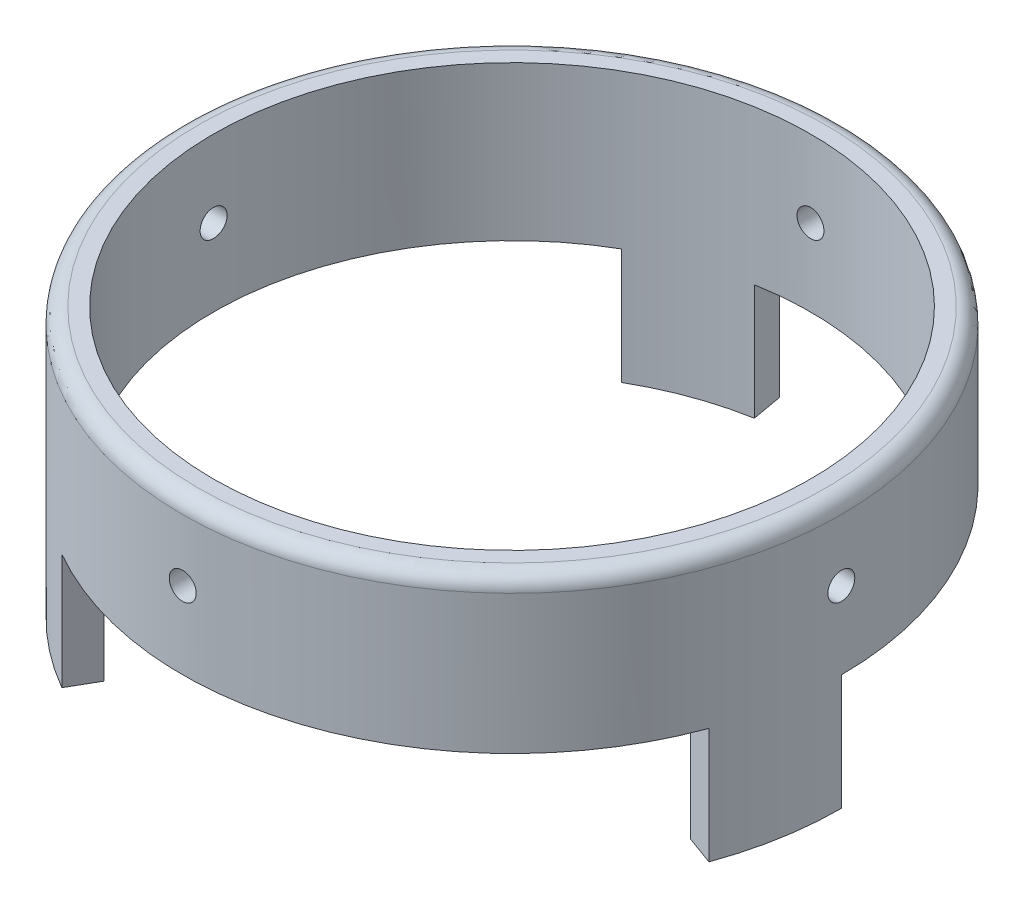
from build123d import *

# Parameters (mm, degrees)
SKETCH1_R               = 42.75
SKETCH1_R_2             = 38.75
BOSS_EXTRUDE1_DEPTH     = 20
BOSS_EXTRUDE2_DEPTH     = 15
SKETCH3_R               = 1.75
CUT_EXTRUDE1_DEPTH      = 43.75
CUT_EXTRUDE1_DEPTH_BACK = 43.75
SKETCH4_R               = 1.75
CUT_EXTRUDE2_DEPTH      = 43.7500001
CUT_EXTRUDE2_DEPTH_BACK = 43.7500001
FILLET1_R               = 2


with BuildPart() as part:
    # Sketch1 → Boss-Extrude1 (new body)
    with BuildSketch(Plane(origin=(0, 0, 0), x_dir=(1, 0, 0), z_dir=(0, 1, 0))):
        Circle(SKETCH1_R)
        Circle(SKETCH1_R_2, mode=Mode.SUBTRACT)
    extrude(amount=BOSS_EXTRUDE1_DEPTH)

    # Sketch2 → Boss-Extrude2 (add)
    with BuildSketch(Plane.XZ):
        with BuildLine():
            Line((40.171859539, 14.621361127), (36.413089055, 13.253280554))
            ThreePointArc((36.413089055, 13.253280554), (38.161300429, 6.728866885), (38.75, 0))
            Line((38.75, 0), (42.75, 0))
            ThreePointArc((42.75, 0), (42.100531441, 7.423459595), (40.171859539, 14.621361127))
        make_face()
        with BuildLine():
            Line((-7.423459595, -42.100531441), (-6.728866885, -38.161300429))
            ThreePointArc((-6.728866885, -38.161300429), (-13.253280554, -36.413089056), (-19.375, -33.558484397))
            Line((-19.375, -33.558484397), (-21.375, -37.022586012))
            ThreePointArc((-21.375, -37.022586012), (-14.621361127, -40.171859539), (-7.423459595, -42.100531441))
        make_face()
        with BuildLine():
            Line((-32.748399943, 27.479170314), (-29.684222171, 24.908019875))
            ThreePointArc((-29.684222171, 24.908019875), (-24.908019875, 29.684222171), (-19.375, 33.558484397))
            Line((-19.375, 33.558484397), (-21.375, 37.022586012))
            ThreePointArc((-21.375, 37.022586012), (-27.479170314, 32.748399943), (-32.748399943, 27.479170314))
        make_face()
    extrude(amount=BOSS_EXTRUDE2_DEPTH)

    # Sketch3 → Cut-Extrude1 (cut, two sides)
    with BuildSketch(Plane.XY) as cut_extrude1_sk:
        with Locations((0, 10)):
            Circle(SKETCH3_R)
    extrude(amount=CUT_EXTRUDE1_DEPTH, mode=Mode.SUBTRACT)
    extrude(cut_extrude1_sk.sketch, amount=-CUT_EXTRUDE1_DEPTH_BACK, mode=Mode.SUBTRACT)

    # Sketch4 → Cut-Extrude2 (cut, two sides)
    with BuildSketch(Plane(origin=(0, 0, 0), x_dir=(0, 0, -1), z_dir=(1, 0, 0))) as cut_extrude2_sk:
        with Locations((0, 10)):
            Circle(SKETCH4_R)
    extrude(amount=CUT_EXTRUDE2_DEPTH, mode=Mode.SUBTRACT)
    extrude(cut_extrude2_sk.sketch, amount=-CUT_EXTRUDE2_DEPTH_BACK, mode=Mode.SUBTRACT)

    # Fillet1
    fillet1_edges = [part.edges().sort_by_distance(p)[0] for p in [
        (-42.75, 20, 0),
    ]]
    fillet(fillet1_edges, radius=FILLET1_R)


solid = part.part
